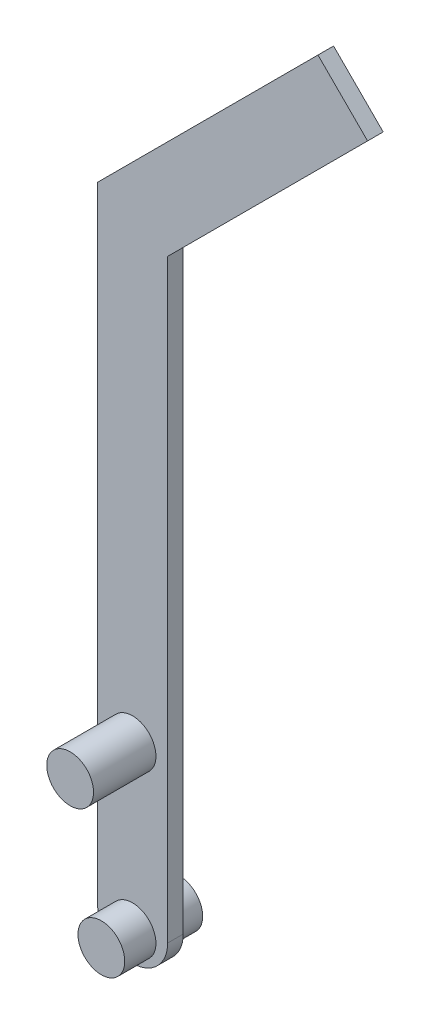
from build123d import *

# Parameters (mm, degrees)
EXTRUDE_1_DEPTH      = 2
SKETCH_2_R           = 3
EXTRUDE_2_DEPTH      = 8
SKETCH_3_R           = 3
EXTRUDE_3_DEPTH      = 4
EXTRUDE_3_DEPTH_BACK = 6
EXTRUDE_4_DEPTH      = 2
SCALE_3_SCALE        = 3.5


with BuildPart() as part:
    # 草图1 → 凸台-拉伸1 (new body)
    with BuildSketch(Plane.XY):
        with BuildLine():
            Line((-4.5, -20), (-4.5, 20))
            ThreePointArc((-4.5, 20), (0, 24.5), (4.5, 20))
            Line((4.5, 20), (4.5, -20))
            ThreePointArc((4.5, -20), (0, -24.5), (-4.5, -20))
        make_face()
    extrude(amount=EXTRUDE_1_DEPTH)

    # 草图2 → 凸台-拉伸2 (add)
    with BuildSketch(Plane.XY.offset(2)):
        Circle(SKETCH_2_R)
    extrude(amount=EXTRUDE_2_DEPTH)

    # 草图3 → 凸台-拉伸3 (add, two sides)
    with BuildSketch(Plane.XY.offset(2)) as extrude_3_sk:
        with Locations((0, -20.775035614)):
            Circle(SKETCH_3_R)
    extrude(amount=EXTRUDE_3_DEPTH)
    extrude(extrude_3_sk.sketch, amount=-EXTRUDE_3_DEPTH_BACK)

    # 草图4 → 凸台-拉伸4 (add)
    with BuildSketch(Plane.XY.offset(2)):
        Polygon((-4.5, 60), (-4.5, 20), (4.5, 20), (4.5, 56.272077939), (30.148232278, 81.920310217), (23.784271247, 88.284271247), align=None)
    extrude(amount=-EXTRUDE_4_DEPTH)


with BuildPart() as part_1:
    # 缩放比例3: scaled about (3.511892573, 26.803081313, 1.433505164)
    add(part.part.scale(SCALE_3_SCALE).moved(Location((-8.779731433, -67.007703283, -3.58376291))))


solid = part_1.part
